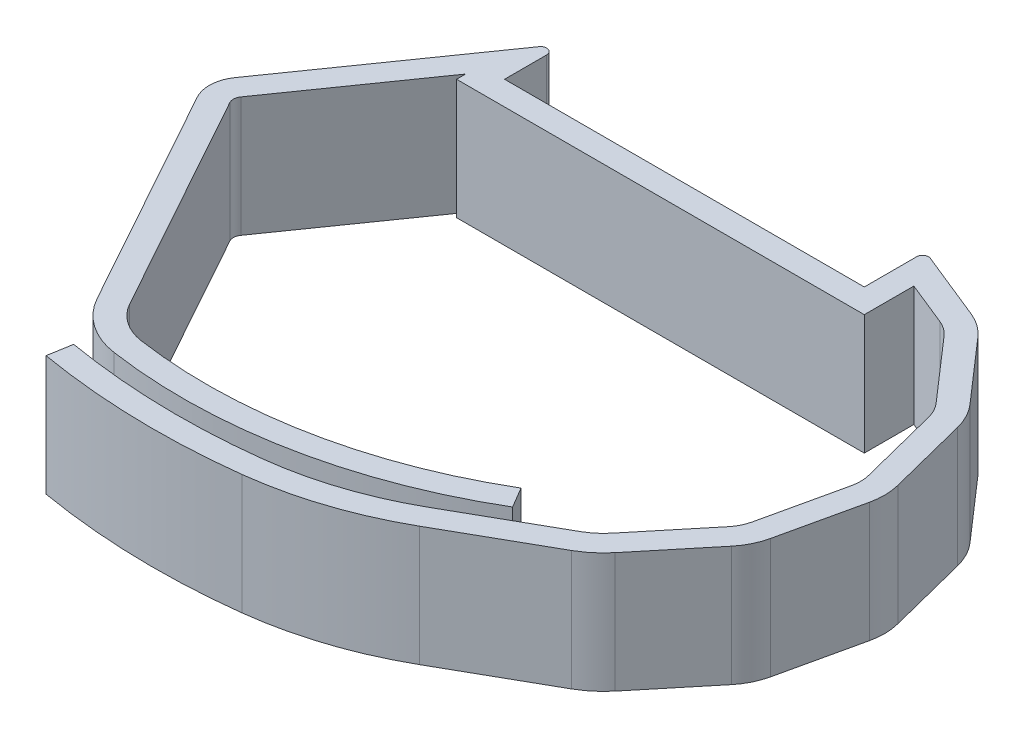
from build123d import *

# Parameters (mm, degrees)
EXTRUDE_THIN1_DEPTH = 10
FILLET1_R           = 0.5


with BuildPart() as part:
    # Sketch1 → Extrude-Thin1 (new body)
    with BuildSketch(Plane(origin=(0, 0, 0), x_dir=(1, 0, 0), z_dir=(0, 1, 0))):
        with BuildLine():
            ThreePointArc((31.228009552, -30.556896247), (17.805759331, -35.661082732), (3.450021006, -36.010793734))
            ThreePointArc((3.450021006, -36.010793734), (0.781528732, -34.960126351), (-1.143442514, -32.834276246))
            Line((-1.143442514, -32.834276246), (-11.514158233, -14.115081405))
            ThreePointArc((-11.514158233, -14.115081405), (-11.864920764, -12.594591782), (-11.35681344, -11.119210477))
            Line((-11.35681344, -11.119210477), (0, 5.1))
            Line((0, 5.1), (0, 0))
            Line((0, 0), (30, 0))
            Line((30, 0), (30, 5.1))
            Line((30, 5.1), (36.395958363, 2.511232605))
            ThreePointArc((36.395958363, 2.511232605), (37.463728778, 1.925417586), (38.366240646, 1.107624688))
            Line((38.366240646, 1.107624688), (42.902523658, -4.091619145))
            ThreePointArc((42.902523658, -4.091619145), (43.590417547, -5.096663868), (44.026071732, -6.233993339))
            Line((44.026071732, -6.233993339), (45.723869414, -12.921854211))
            ThreePointArc((45.723869414, -12.921854211), (45.883457457, -14.129266548), (45.7582513, -15.340726954))
            Line((45.7582513, -15.340726954), (44.251223786, -22.074141249))
            ThreePointArc((44.251223786, -22.074141249), (43.848071102, -23.223393532), (43.189020782, -24.247583736))
            Line((43.189020782, -24.247583736), (38.802344779, -29.573658617))
            ThreePointArc((38.802344779, -29.573658617), (37.883123065, -30.501625481), (36.810104599, -31.246422387))
            Line((36.810104599, -31.246422387), (28.716751538, -35.827648886))
            ThreePointArc((28.716751538, -35.827648886), (23.339920043, -38.206219709), (17.601311476, -39.485394366))
            ThreePointArc((17.601311476, -39.485394366), (9.20703571, -39.890619172), (0.842295428, -39.078712278))
            Line((0.842295428, -39.078712278), (1.179197641, -37.107292257))
            ThreePointArc((1.179197641, -37.107292257), (9.255554358, -37.891207773), (17.360428291, -37.499953535))
            ThreePointArc((17.360428291, -37.499953535), (22.714760553, -36.306436666), (27.731541539, -34.087142851))
            Line((27.731541539, -34.087142851), (35.824894599, -29.505916352))
            ThreePointArc((35.824894599, -29.505916352), (36.597062561, -28.969943927), (37.258554958, -28.302158326))
            Line((37.258554958, -28.302158326), (41.645230962, -22.976083445))
            ThreePointArc((41.645230962, -22.976083445), (42.051182062, -22.345219415), (42.299509498, -21.63732168))
            Line((42.299509498, -21.63732168), (43.806537012, -14.903907385))
            ThreePointArc((43.806537012, -14.903907385), (43.883659464, -14.157691701), (43.785359016, -13.413969481))
            Line((43.785359016, -13.413969481), (42.087561335, -6.72610861))
            ThreePointArc((42.087561335, -6.72610861), (41.819214153, -6.025554893), (41.39549646, -5.406483786))
            Line((41.39549646, -5.406483786), (36.859213448, -0.207239953))
            ThreePointArc((36.859213448, -0.207239953), (36.303298861, 0.29649082), (35.645591002, 0.657331631))
            Line((35.645591002, 0.657331631), (32, 2.13288644))
            Line((32, 2.13288644), (32, -2))
            Line((32, -2), (-2, -2))
            Line((-2, -2), (-2, -1.243189605))
            Line((-2, -1.243189605), (-9.718509351, -12.26636335))
            ThreePointArc((-9.718509351, -12.26636335), (-9.867673478, -12.69948831), (-9.764700771, -13.145855637))
            Line((-9.764700771, -13.145855637), (0.606014947, -31.865050477))
            ThreePointArc((0.606014947, -31.865050477), (1.919083649, -33.31514343), (3.73932574, -34.031828659))
            ThreePointArc((3.73932574, -34.031828659), (17.420438321, -33.698551784), (30.211930629, -28.834228658))
            Line((30.211930629, -28.834228658), (31.228009552, -30.556896247))
        make_face()
    extrude(amount=EXTRUDE_THIN1_DEPTH)

    # Fillet1
    fillet1_edges = [part.edges().sort_by_distance(p)[0] for p in [
        (0, 5, -5.1),
        (30, 5, -5.1),
    ]]
    fillet(fillet1_edges, radius=FILLET1_R)


solid = part.part
